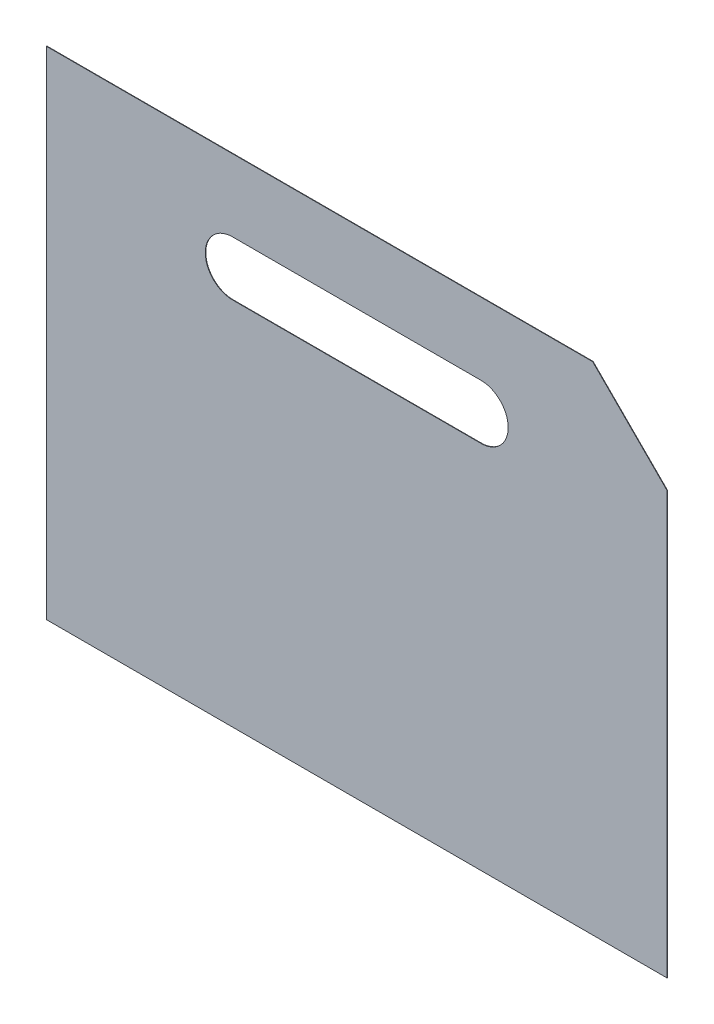
from build123d import *

# Parameters (mm, degrees)
SKIZZE1_W                       = 250
SKIZZE1_H                       = 200
AUFSATZ_LINEAR_AUSTRAGEN1_DEPTH = 0.19
SCHNITT_LINEAR_AUSTRAGEN1_DEPTH = 1.19


with BuildPart() as part:
    # Skizze1 → Aufsatz-Linear austragen1 (new body)
    with BuildSketch(Plane.XY):
        with Locations((125, 100)):
            Rectangle(SKIZZE1_W, SKIZZE1_H)
    extrude(amount=AUFSATZ_LINEAR_AUSTRAGEN1_DEPTH)

    # Skizze2 → Schnitt-Linear austragen1 (cut, through all)
    with BuildSketch(Plane.XY.offset(0.19)):
        with BuildLine():
            Line((75, 171), (175, 171))
            ThreePointArc((175, 171), (186, 160), (175, 149))
            Line((175, 149), (75, 149))
            ThreePointArc((75, 149), (64, 160), (75, 171))
        make_face()
        Polygon((220, 200), (250, 170), (250, 200), align=None)
    extrude(amount=-SCHNITT_LINEAR_AUSTRAGEN1_DEPTH, mode=Mode.SUBTRACT)


solid = part.part
